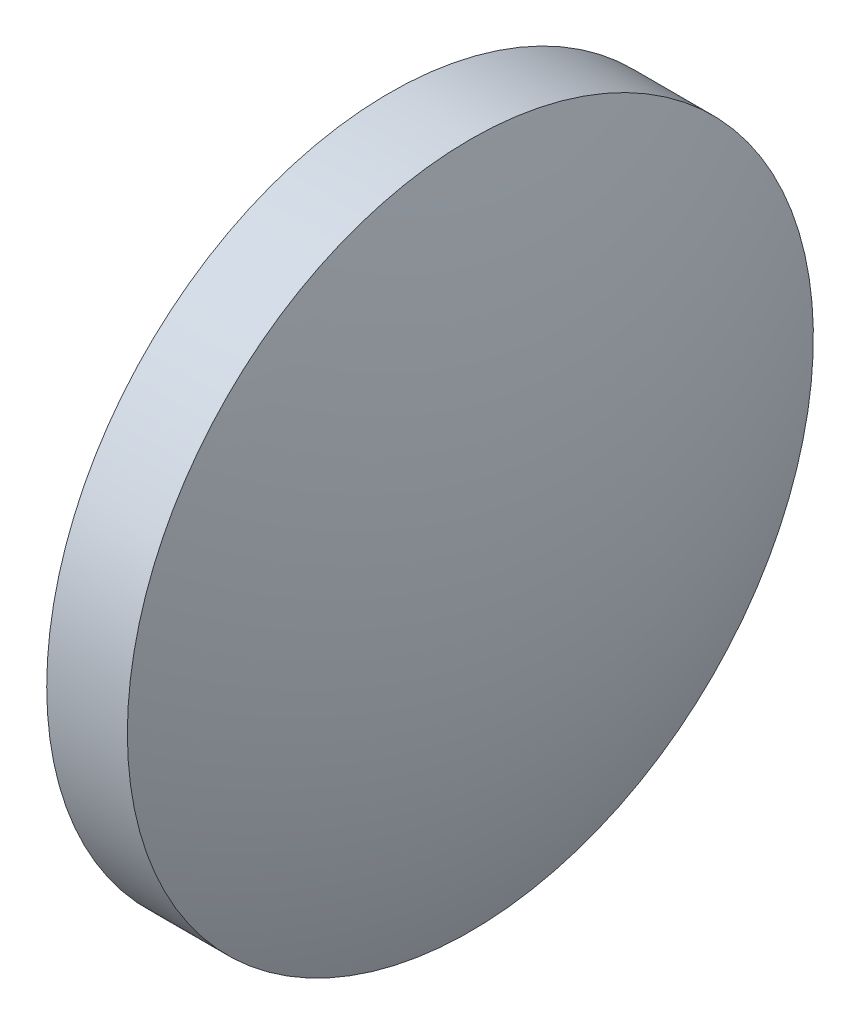
from build123d import *


with BuildPart() as part:
    # 草图1 → 旋转1 (revolve)
    with BuildSketch(Plane.XY):
        with BuildLine():
            Line((115.773606431, 65.233554926), (115.773606431, 77.933554926))
            Line((115.773606431, 77.933554926), (118.759465862, 77.933554926))
            ThreePointArc((118.759465862, 77.933554926), (120.570662778, 71.698010915), (121.181606431, 65.233554926))
            Line((121.181606431, 65.233554926), (115.773606431, 65.233554926))
        make_face()
    revolve(axis=Axis((110.165373228, 65.233554926, 0), (1, 0, 0)))


solid = part.part
